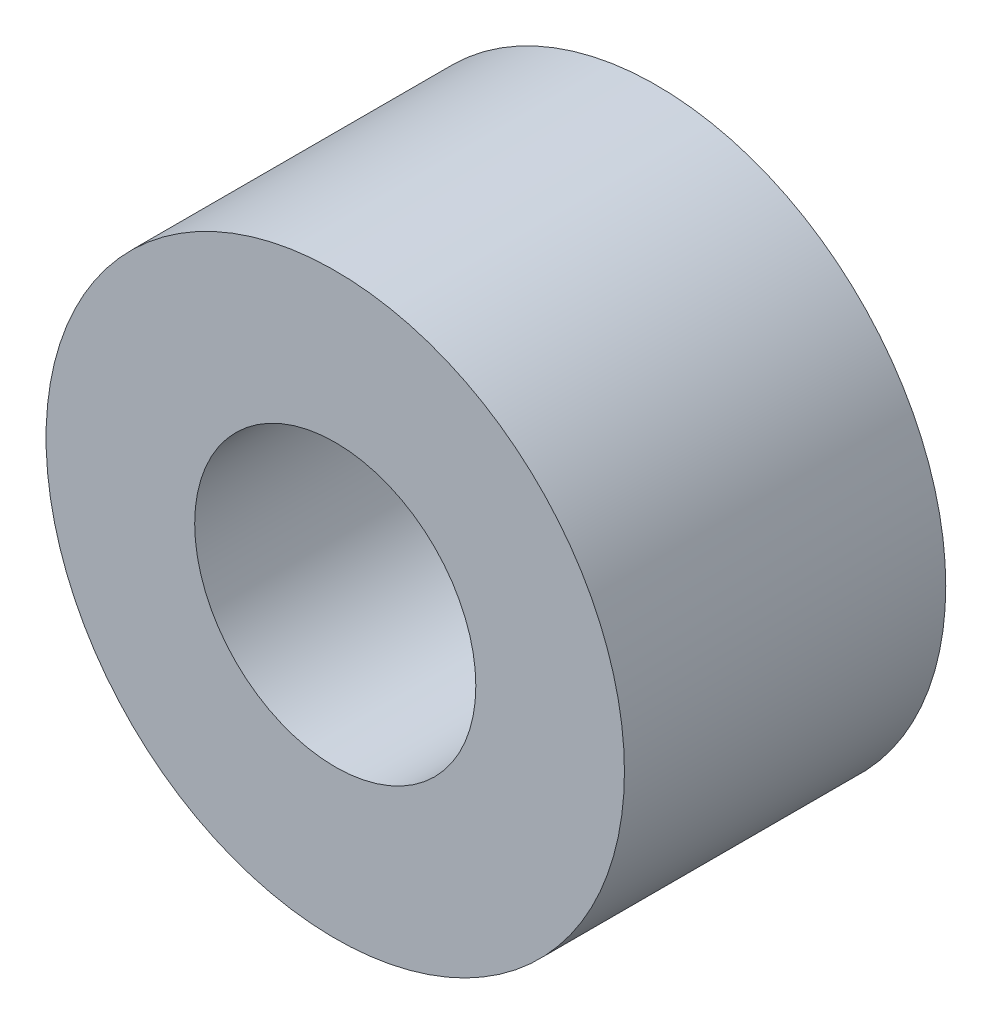
from build123d import *

# Parameters (mm, degrees)
SKETCH_1_R             = 18
EXTRUDE_1_DEPTH        = 20
HOLE_WIZARD_M201_D     = 17.5
HOLE_WIZARD_M201_DEPTH = 52.5
HOLE_WIZARD_M201_TIP   = 5.257530416


with BuildPart() as part:
    # Эскиз1 → Бобышка-Вытянуть1 (new body)
    with BuildSketch(Plane.XY):
        Circle(SKETCH_1_R)
    extrude(amount=EXTRUDE_1_DEPTH)

    # Отверстие обработанное метчиком M201
    with Locations(Plane(origin=(0, 0, 0), x_dir=(-1, 0, 0), z_dir=(0, 0, -1))):
        with Locations((0, 0)):
            Hole(HOLE_WIZARD_M201_D / 2, depth=HOLE_WIZARD_M201_DEPTH)
            with Locations((0, 0, -(HOLE_WIZARD_M201_DEPTH + HOLE_WIZARD_M201_TIP / 2))):  # 118° drill point
                Cone(0, HOLE_WIZARD_M201_D / 2, HOLE_WIZARD_M201_TIP, mode=Mode.SUBTRACT)


solid = part.part
